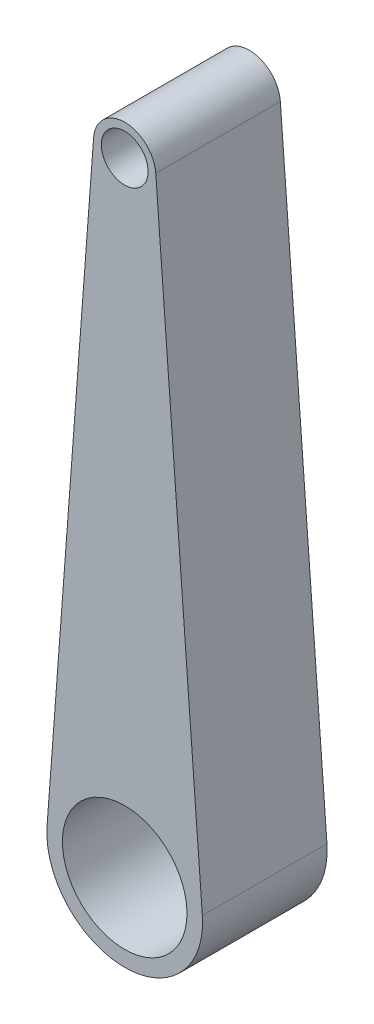
from build123d import *

# Parameters (mm, degrees)
IZIM1_R                     = 0.75
IZIM1_R_2                   = 2.5
IZIM1_R_3                   = 2
Y_KSEKLIK_EKSTR_ZYON1_DEPTH = 2


with BuildPart() as part:
    # Çizim1 → Yükseklik-Ekstrüzyon1 (new body, symmetric)
    with BuildSketch(Plane.XY):
        with BuildLine():
            Line((-0.997183534, 20.075), (-2.492958834, 0.1875))
            ThreePointArc((-2.492958834, 0.1875), (0, 2.5), (2.492958834, 0.1875))
            Line((2.492958834, 0.1875), (0.997183534, 20.075))
            ThreePointArc((0.997183534, 20.075), (0, 21), (-0.997183534, 20.075))
        make_face()
        with Locations((0, 20)):
            Circle(IZIM1_R, mode=Mode.SUBTRACT)
        Circle(IZIM1_R_2)
        Circle(IZIM1_R_3, mode=Mode.SUBTRACT)
    extrude(amount=Y_KSEKLIK_EKSTR_ZYON1_DEPTH, both=True)


solid = part.part
